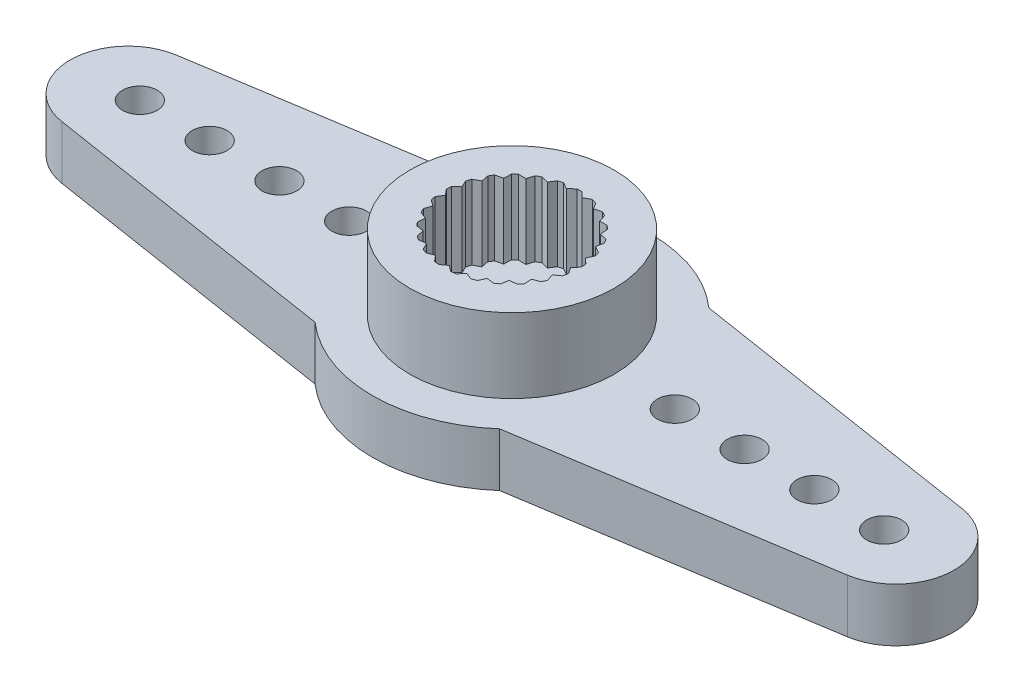
from build123d import *

# Parameters (mm, degrees)
BOSS_EXTRUDE1_DEPTH            = 2.3
SKETCH2_R                      = 4.4
BOSS_EXTRUDE2_DEPTH            = 3.2
CUT_EXTRUDE1_DEPTH             = 3.2
F_1_5_1_5_DIAMETER_HOLE1_D     = 1.5
F_1_5_1_5_DIAMETER_HOLE1_DEPTH = 5.5
F_3_0_3_DIAMETER_HOLE1_D       = 3
F_3_0_3_DIAMETER_HOLE1_DEPTH   = 5.5


with BuildPart() as part:
    # Sketch1 → Boss-Extrude1 (new body)
    with BuildSketch(Plane(origin=(0, 1.15, 0), x_dir=(1, 0, 0), z_dir=(0, 1, 0))):
        with BuildLine():
            Line((-3.968626967, 4.5), (-16.888114198, 2.469689731))
            ThreePointArc((-16.888114198, 2.469689731), (-19, 0), (-16.888114198, -2.469689731))
            Line((-16.888114198, -2.469689731), (-3.968626967, -4.5))
            ThreePointArc((-3.968626967, -4.5), (0, -6), (3.968626967, -4.5))
            Line((3.968626967, -4.5), (16.888114198, -2.469689731))
            ThreePointArc((16.888114198, -2.469689731), (19, 0), (16.888114198, 2.469689731))
            Line((16.888114198, 2.469689731), (3.968626967, 4.5))
            ThreePointArc((3.968626967, 4.5), (0, 6), (-3.968626967, 4.5))
        make_face()
    extrude(amount=-BOSS_EXTRUDE1_DEPTH)

    # Sketch2 → Boss-Extrude2 (add)
    with BuildSketch(Plane(origin=(0, 1.15, 0), x_dir=(-1, 0, 0), z_dir=(0, 1, 0))):
        Circle(SKETCH2_R)
    extrude(amount=BOSS_EXTRUDE2_DEPTH)

    # Sketch3 → Cut-Extrude1 (cut)
    with BuildSketch(Plane(origin=(0, 4.35, 0), x_dir=(-1, 0, 0), z_dir=(0, 1, 0))):
        with BuildLine():
            Line((-0.61665913, -2.83367809), (-0.338399731, -2.678709694))
            Line((-0.338399731, -2.678709694), (-0.107421435, -2.898009771))
            ThreePointArc((-0.107421435, -2.898009771), (0, -2.9), (0.107421435, -2.898009771))
            Line((0.107421435, -2.898009771), (0.338399731, -2.678709694))
            Line((0.338399731, -2.678709694), (0.61665913, -2.83367809))
            ThreePointArc((0.61665913, -2.83367809), (0.721200673, -2.808891167), (0.824752316, -2.780248841))
            Line((0.824752316, -2.780248841), (0.993936292, -2.510396512))
            Line((0.993936292, -2.510396512), (1.301992734, -2.591295993))
            ThreePointArc((1.301992734, -2.591295993), (1.397085655, -2.541289372), (1.490260976, -2.48779465))
            Line((1.490260976, -2.48779465), (1.587020181, -2.184345885))
            Line((1.587020181, -2.184345885), (1.905517346, -2.186093238))
            ThreePointArc((1.905517346, -2.186093238), (1.985186607, -2.11400902), (2.062131058, -2.039023173))
            Line((2.062131058, -2.039023173), (2.080385755, -1.721044772))
            Line((2.080385755, -1.721044772), (2.389311295, -1.643530205))
            ThreePointArc((2.389311295, -1.643530205), (2.448550984, -1.553897705), (2.504429862, -1.46213237))
            Line((2.504429862, -1.46213237), (2.443033042, -1.149604087))
            Line((2.443033042, -1.149604087), (2.722976028, -0.997698125))
            ThreePointArc((2.722976028, -0.997698125), (2.758063897, -0.896149284), (2.789366126, -0.793370413))
            Line((2.789366126, -0.793370413), (2.652175577, -0.505929549))
            Line((2.652175577, -0.505929549), (2.885546163, -0.289177003))
            ThreePointArc((2.885546163, -0.289177003), (2.894277512, -0.182092507), (2.899036259, -0.074758075))
            Line((2.899036259, -0.074758075), (2.694672167, 0.169534403))
            Line((2.694672167, 0.169534403), (2.866806821, 0.437514174))
            ThreePointArc((2.866806821, 0.437514174), (2.848633027, 0.543405812), (2.826549281, 0.648551587))
            Line((2.826549281, 0.648551587), (2.567852594, 0.834345885))
            Line((2.567852594, 0.834345885), (2.667935462, 1.136714727))
            ThreePointArc((2.667935462, 1.136714727), (2.623998452, 1.234759946), (2.576459817, 1.331110368))
            Line((2.576459817, 1.331110368), (2.279685399, 1.446732346))
            Line((2.279685399, 1.446732346), (2.301427906, 1.764491312))
            ThreePointArc((2.301427906, 1.764491312), (2.234488404, 1.84852957), (2.164481907, 1.930030589))
            Line((2.164481907, 1.930030589), (1.848277186, 1.968215294))
            Line((1.848277186, 1.968215294), (1.790313171, 2.281398419))
            ThreePointArc((1.790313171, 2.281398419), (1.704577232, 2.346149284), (1.616501638, 2.40767989))
            Line((1.616501638, 2.40767989), (1.30073492, 2.366028036))
            Line((1.30073492, 2.366028036), (1.166706475, 2.654956874))
            ThreePointArc((1.166706475, 2.654956874), (1.067561203, 2.696351809), (0.966950626, 2.734045809))
            Line((0.966950626, 2.734045809), (0.671462695, 2.615174535))
            Line((0.671462695, 2.615174535), (0.469791321, 2.861694623))
            ThreePointArc((0.469791321, 2.861694623), (0.363466377, 2.877132634), (0.25664255, 2.888621575))
            Line((0.25664255, 2.888621575), (0, 2.7))
            Line((0, 2.7), (-0.25664255, 2.888621575))
            ThreePointArc((-0.25664255, 2.888621575), (-0.363466377, 2.877132634), (-0.469791321, 2.861694623))
            Line((-0.469791321, 2.861694623), (-0.671462695, 2.615174535))
            Line((-0.671462695, 2.615174535), (-0.966950626, 2.734045809))
            ThreePointArc((-0.966950626, 2.734045809), (-1.067561203, 2.696351809), (-1.166706475, 2.654956874))
            Line((-1.166706475, 2.654956874), (-1.30073492, 2.366028036))
            Line((-1.30073492, 2.366028036), (-1.616501638, 2.40767989))
            ThreePointArc((-1.616501638, 2.40767989), (-1.704577232, 2.346149284), (-1.790313171, 2.281398419))
            Line((-1.790313171, 2.281398419), (-1.848277186, 1.968215294))
            Line((-1.848277186, 1.968215294), (-2.164481907, 1.930030589))
            ThreePointArc((-2.164481907, 1.930030589), (-2.234488404, 1.84852957), (-2.301427906, 1.764491312))
            Line((-2.301427906, 1.764491312), (-2.279685399, 1.446732346))
            Line((-2.279685399, 1.446732346), (-2.576459817, 1.331110368))
            ThreePointArc((-2.576459817, 1.331110368), (-2.623998452, 1.234759946), (-2.667935462, 1.136714727))
            Line((-2.667935462, 1.136714727), (-2.567852594, 0.834345885))
            Line((-2.567852594, 0.834345885), (-2.826549281, 0.648551587))
            ThreePointArc((-2.826549281, 0.648551587), (-2.848633027, 0.543405812), (-2.866806821, 0.437514174))
            Line((-2.866806821, 0.437514174), (-2.694672167, 0.169534403))
            Line((-2.694672167, 0.169534403), (-2.899036259, -0.074758075))
            ThreePointArc((-2.899036259, -0.074758075), (-2.894277512, -0.182092507), (-2.885546163, -0.289177003))
            Line((-2.885546163, -0.289177003), (-2.652175577, -0.505929549))
            Line((-2.652175577, -0.505929549), (-2.789366126, -0.793370413))
            ThreePointArc((-2.789366126, -0.793370413), (-2.758063897, -0.896149284), (-2.722976028, -0.997698125))
            Line((-2.722976028, -0.997698125), (-2.443033042, -1.149604087))
            Line((-2.443033042, -1.149604087), (-2.504429862, -1.46213237))
            ThreePointArc((-2.504429862, -1.46213237), (-2.448550984, -1.553897705), (-2.389311295, -1.643530205))
            Line((-2.389311295, -1.643530205), (-2.080385755, -1.721044772))
            Line((-2.080385755, -1.721044772), (-2.062131058, -2.039023173))
            ThreePointArc((-2.062131058, -2.039023173), (-1.985186607, -2.11400902), (-1.905517346, -2.186093238))
            Line((-1.905517346, -2.186093238), (-1.587020181, -2.184345885))
            Line((-1.587020181, -2.184345885), (-1.490260976, -2.48779465))
            ThreePointArc((-1.490260976, -2.48779465), (-1.397085655, -2.541289372), (-1.301992734, -2.591295993))
            Line((-1.301992734, -2.591295993), (-0.993936292, -2.510396512))
            Line((-0.993936292, -2.510396512), (-0.824752316, -2.780248841))
            ThreePointArc((-0.824752316, -2.780248841), (-0.721200673, -2.808891167), (-0.61665913, -2.83367809))
        make_face()
    extrude(amount=-CUT_EXTRUDE1_DEPTH, mode=Mode.SUBTRACT)

    # Ø1.5 (1.5) Diameter Hole1
    with Locations(Plane(origin=(0, -1.15, 0), x_dir=(-1, 0, 0), z_dir=(0, -1, 0))):
        with Locations((-7, 0), (-16, 0), (-13, 0), (-10, 0), (7, 0), (16, 0), (13, 0), (10, 0)):
            Hole(F_1_5_1_5_DIAMETER_HOLE1_D / 2, depth=F_1_5_1_5_DIAMETER_HOLE1_DEPTH)

    # Ø3.0 (3) Diameter Hole1
    with Locations(Plane(origin=(0, -1.15, 0), x_dir=(-1, 0, 0), z_dir=(0, -1, 0))):
        with Locations((0, 0)):
            Hole(F_3_0_3_DIAMETER_HOLE1_D / 2, depth=F_3_0_3_DIAMETER_HOLE1_DEPTH)


solid = part.part
